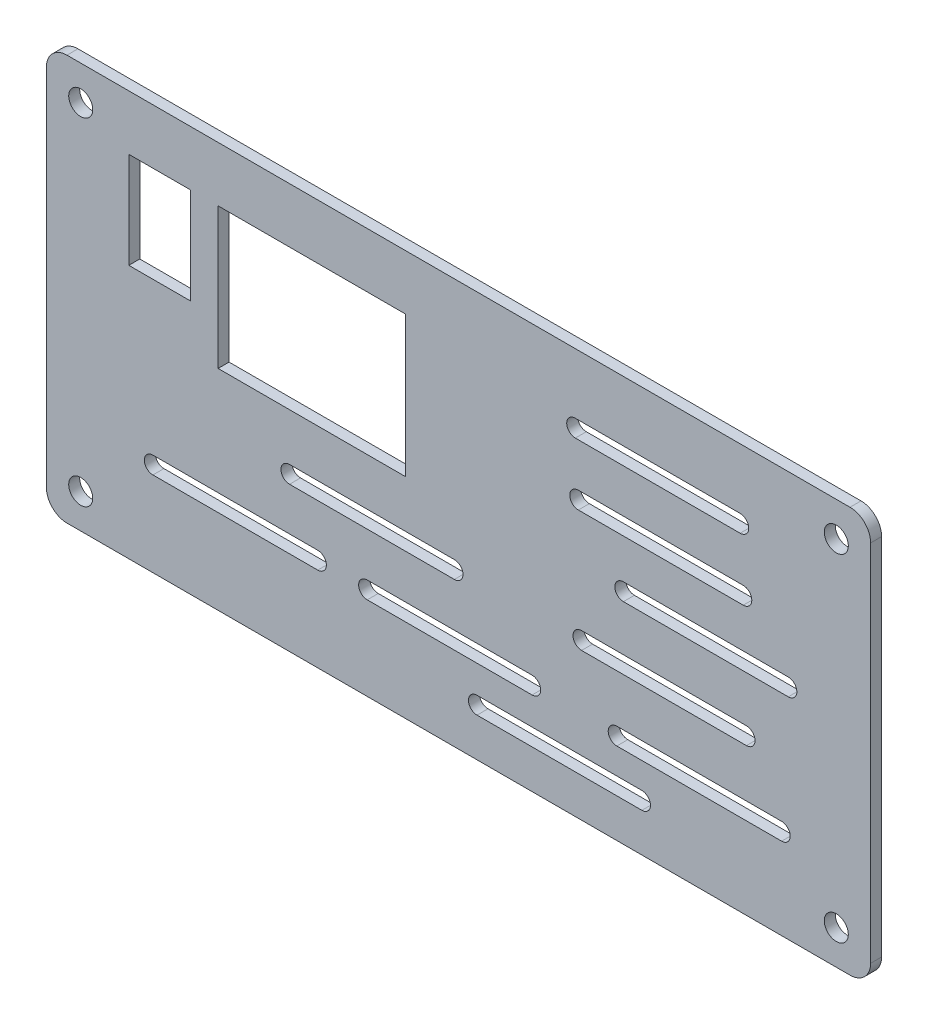
from build123d import *

# Parameters (mm, degrees)
SKETCH_2_R      = 1.75
SKETCH_2_W      = 27.3
SKETCH_2_H      = 20.5
SKETCH_2_W_2    = 9
SKETCH_2_H_2    = 14
EXTRUDE_1_DEPTH = 1.6


with BuildPart() as part:
    # 草图2 → 凸台-拉伸1 (new body)
    with BuildSketch(Plane.XY):
        with BuildLine():
            Line((137.6194709, 153.362234659), (251.6194709, 153.362234659))
            ThreePointArc((251.6194709, 153.362234659), (253.740791244, 152.483555002), (254.6194709, 150.362234659))
            Line((254.6194709, 150.362234659), (254.6194709, 97.362234659))
            ThreePointArc((254.6194709, 97.362234659), (253.740791244, 95.240914315), (251.6194709, 94.362234659))
            Line((251.6194709, 94.362234659), (137.6194709, 94.362234659))
            ThreePointArc((137.6194709, 94.362234659), (135.498150556, 95.240914315), (134.6194709, 97.362234659))
            Line((134.6194709, 97.362234659), (134.6194709, 150.362234659))
            ThreePointArc((134.6194709, 150.362234659), (135.498150556, 152.483555002), (137.6194709, 153.362234659))
        make_face()
        with Locations((139.6194709, 99.362234659)):
            Circle(SKETCH_2_R, mode=Mode.SUBTRACT)
        with Locations((249.6194709, 99.362234659)):
            Circle(SKETCH_2_R, mode=Mode.SUBTRACT)
        with Locations((249.6194709, 148.362234659)):
            Circle(SKETCH_2_R, mode=Mode.SUBTRACT)
        with Locations((139.6194709, 148.362234659)):
            Circle(SKETCH_2_R, mode=Mode.SUBTRACT)
        with Locations((173.2694709, 135.112234659)):
            Rectangle(SKETCH_2_W, SKETCH_2_H, mode=Mode.SUBTRACT)
        with BuildLine():
            Line((211.624069471, 144.588100568), (235.624069471, 144.588100568))
            ThreePointArc((235.624069471, 144.588100568), (236.874069471, 143.338100568), (235.624069471, 142.088100568))
            Line((235.624069471, 142.088100568), (211.624069471, 142.088100568))
            ThreePointArc((211.624069471, 142.088100568), (210.374069471, 143.338100568), (211.624069471, 144.588100568))
        make_face(mode=Mode.SUBTRACT)
        with BuildLine():
            Line((212.067868177, 135.739898553), (236.067868177, 135.739898553))
            ThreePointArc((236.067868177, 135.739898553), (237.317868177, 134.489898553), (236.067868177, 133.239898553))
            Line((236.067868177, 133.239898553), (212.067868177, 133.239898553))
            ThreePointArc((212.067868177, 133.239898553), (210.817868177, 134.489898553), (212.067868177, 135.739898553))
        make_face(mode=Mode.SUBTRACT)
        with BuildLine():
            Line((212.536781854, 118.268660205), (236.536781854, 118.268660205))
            ThreePointArc((236.536781854, 118.268660205), (237.786781854, 117.018660205), (236.536781854, 115.768660205))
            Line((236.536781854, 115.768660205), (212.536781854, 115.768660205))
            ThreePointArc((212.536781854, 115.768660205), (211.286781854, 117.018660205), (212.536781854, 118.268660205))
        make_face(mode=Mode.SUBTRACT)
        with BuildLine():
            Line((150.12910228, 109.191368081), (174.12910228, 109.191368081))
            ThreePointArc((174.12910228, 109.191368081), (175.37910228, 107.941368081), (174.12910228, 106.691368081))
            Line((174.12910228, 106.691368081), (150.12910228, 106.691368081))
            ThreePointArc((150.12910228, 106.691368081), (148.87910228, 107.941368081), (150.12910228, 109.191368081))
        make_face(mode=Mode.SUBTRACT)
        with BuildLine():
            Line((181.33094074, 109.046397883), (205.33094074, 109.046397883))
            ThreePointArc((205.33094074, 109.046397883), (206.58094074, 107.796397883), (205.33094074, 106.546397883))
            Line((205.33094074, 106.546397883), (181.33094074, 106.546397883))
            ThreePointArc((181.33094074, 106.546397883), (180.08094074, 107.796397883), (181.33094074, 109.046397883))
        make_face(mode=Mode.SUBTRACT)
        with BuildLine():
            Line((217.663513674, 108.782143694), (241.663513674, 108.782143694))
            ThreePointArc((241.663513674, 108.782143694), (242.913513674, 107.532143694), (241.663513674, 106.282143694))
            Line((241.663513674, 106.282143694), (217.663513674, 106.282143694))
            ThreePointArc((217.663513674, 106.282143694), (216.413513674, 107.532143694), (217.663513674, 108.782143694))
        make_face(mode=Mode.SUBTRACT)
        with BuildLine():
            Line((218.628069565, 127.463512498), (242.628069565, 127.463512498))
            ThreePointArc((242.628069565, 127.463512498), (243.878069565, 126.213512498), (242.628069565, 124.963512498))
            Line((242.628069565, 124.963512498), (218.628069565, 124.963512498))
            ThreePointArc((218.628069565, 124.963512498), (217.378069565, 126.213512498), (218.628069565, 127.463512498))
        make_face(mode=Mode.SUBTRACT)
        with BuildLine():
            Line((170.018702634, 117.960710868), (194.018702634, 117.960710868))
            ThreePointArc((194.018702634, 117.960710868), (195.268702634, 116.710710868), (194.018702634, 115.460710868))
            Line((194.018702634, 115.460710868), (170.018702634, 115.460710868))
            ThreePointArc((170.018702634, 115.460710868), (168.768702634, 116.710710868), (170.018702634, 117.960710868))
        make_face(mode=Mode.SUBTRACT)
        with BuildLine():
            Line((197.316536613, 102.501223257), (221.316536613, 102.501223257))
            ThreePointArc((221.316536613, 102.501223257), (222.566536613, 101.251223257), (221.316536613, 100.001223257))
            Line((221.316536613, 100.001223257), (197.316536613, 100.001223257))
            ThreePointArc((197.316536613, 100.001223257), (196.066536613, 101.251223257), (197.316536613, 102.501223257))
        make_face(mode=Mode.SUBTRACT)
        with Locations((151.1194709, 138.362234659)):
            Rectangle(SKETCH_2_W_2, SKETCH_2_H_2, mode=Mode.SUBTRACT)
    extrude(amount=EXTRUDE_1_DEPTH)


solid = part.part
